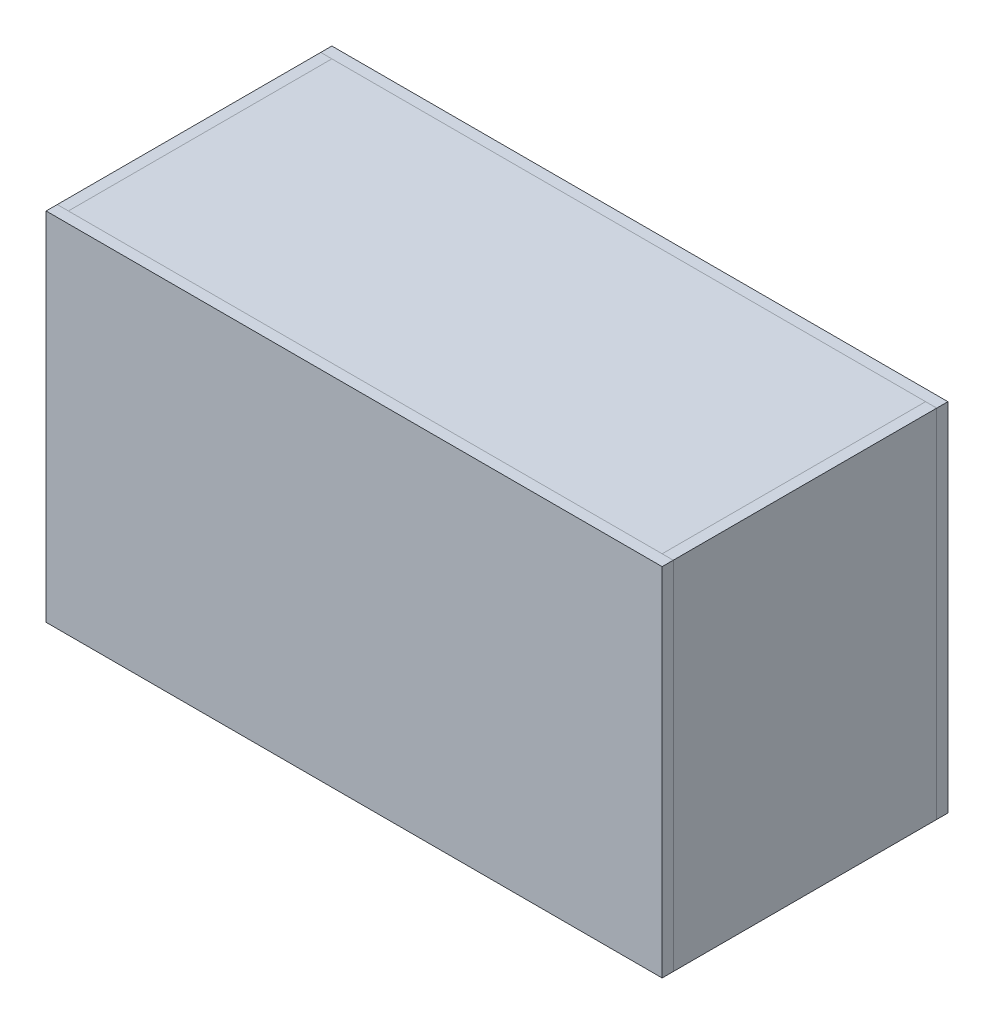
from build123d import *

# Parameters (mm, degrees)
SKETCH1_W           = 1016
SKETCH1_H           = 450.85
BOTTOM_DEPTH        = 19.05
SKETCH2_W           = 450.85
SKETCH2_H           = 609.6
SIDE_DEPTH          = 19.05
SKETCH6_W           = 1054.1
SKETCH6_H           = 609.6
BOSS_EXTRUDE5_DEPTH = 19.05
SKETCH8_W           = 1016
SKETCH8_H           = 450.85
BOSS_EXTRUDE6_DEPTH = 19.05


with BuildPart() as part:
    # Sketch1 → bottom (new body)
    with BuildSketch(Plane(origin=(0, 0, 0), x_dir=(1, 0, 0), z_dir=(0, 1, 0))):
        Rectangle(SKETCH1_W, SKETCH1_H)
    extrude(amount=-BOTTOM_DEPTH)


with BuildPart() as body_2:
    # Sketch2 → side (new body)
    with BuildSketch(Plane.ZY.offset(508)):
        with Locations((0, 285.75)):
            Rectangle(SKETCH2_W, SKETCH2_H)
    extrude(amount=SIDE_DEPTH)


with BuildPart() as body_3:
    # Mirror4: mirrored copy
    add(body_2.part.mirror(Plane(origin=(0, 0, 0), x_dir=(0, 0, 1), z_dir=(1, 0, 0))))


with BuildPart() as body_4:
    # Sketch6 → Boss-Extrude5 (new body)
    with BuildSketch(Plane.XY.offset(225.425)):
        with Locations((0, 285.75)):
            Rectangle(SKETCH6_W, SKETCH6_H)
    extrude(amount=BOSS_EXTRUDE5_DEPTH)


with BuildPart() as body_5:
    # Mirror5: mirrored copy
    add(body_4.part.mirror(Plane.XY))


with BuildPart() as body_6:
    # Sketch8 → Boss-Extrude6 (new body)
    with BuildSketch(Plane(origin=(0, 590.55, 0), x_dir=(1, 0, 0), z_dir=(0, 1, 0))):
        Rectangle(SKETCH8_W, SKETCH8_H)
    extrude(amount=-BOSS_EXTRUDE6_DEPTH)


solid = Compound([part.part, body_2.part, body_3.part, body_4.part, body_5.part, body_6.part])
